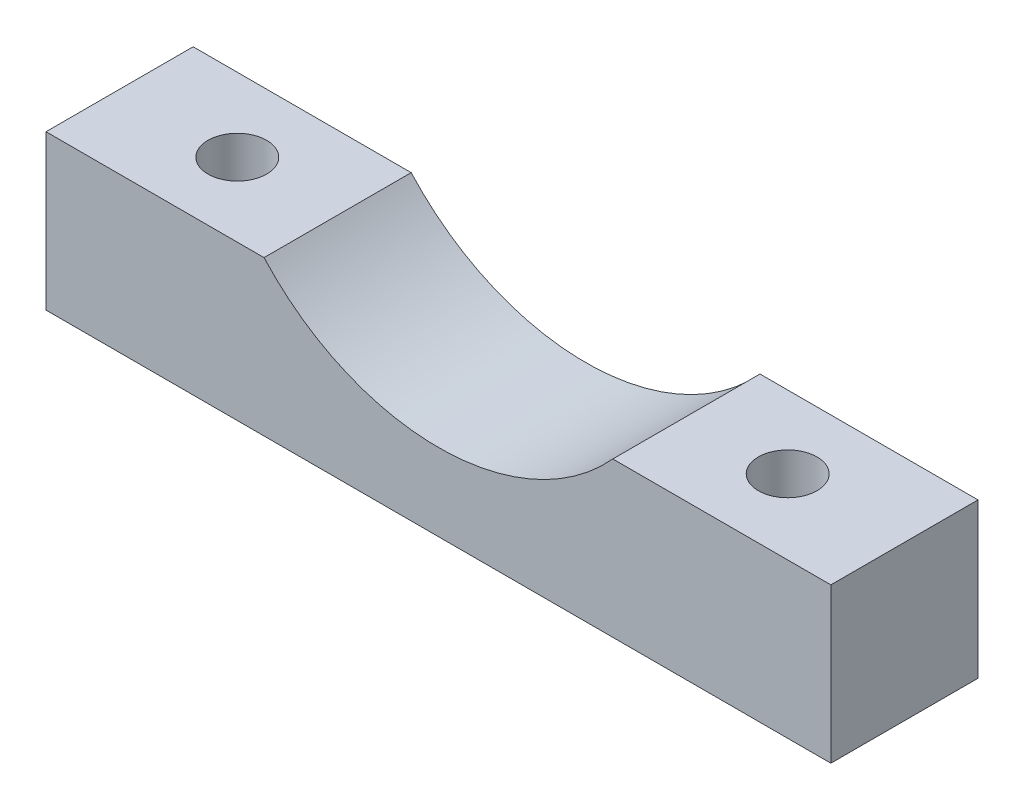
from build123d import *

# Parameters (mm, degrees)
SKETCH1_W                                      = 50.8
SKETCH1_H                                      = 9.525
EXTRUDE1_DEPTH                                 = 10
SKETCH2_R                                      = 15.24
CUT_EXTRUDE1_DEPTH                             = 10.525
CBORE_FOR_6_SOCKET_HEAD_CAP_SCREW1_D           = 3.7973
CBORE_FOR_6_SOCKET_HEAD_CAP_SCREW1_CBORE_D     = 7.14502
CBORE_FOR_6_SOCKET_HEAD_CAP_SCREW1_CBORE_DEPTH = 3.5052


with BuildPart() as part:
    # Sketch1 → Extrude1 (new body)
    with BuildSketch(Plane(origin=(0, 0, 0), x_dir=(1, 0, 0), z_dir=(0, 1, 0))):
        with Locations((-25.4, 4.7625)):
            Rectangle(SKETCH1_W, SKETCH1_H)
    extrude(amount=EXTRUDE1_DEPTH)

    # Sketch2 → Cut-Extrude1 (cut, through all)
    with BuildSketch(Plane(origin=(0, 0, -9.525), x_dir=(-1, 0, 0), z_dir=(0, 0, -1))):
        with Locations((25.4, 20.24)):
            Circle(SKETCH2_R)
    extrude(amount=-CUT_EXTRUDE1_DEPTH, mode=Mode.SUBTRACT)

    # CBORE for #6 Socket Head Cap Screw1 (through all)
    with Locations(Plane(origin=(-43.18, 0, -4.7625), x_dir=(0, 0, -1), z_dir=(0, -1, 0))):
        with Locations((0, 0), (0.0635, 35.559943304)):
            CounterBoreHole(CBORE_FOR_6_SOCKET_HEAD_CAP_SCREW1_D / 2, CBORE_FOR_6_SOCKET_HEAD_CAP_SCREW1_CBORE_D / 2, CBORE_FOR_6_SOCKET_HEAD_CAP_SCREW1_CBORE_DEPTH)


solid = part.part
